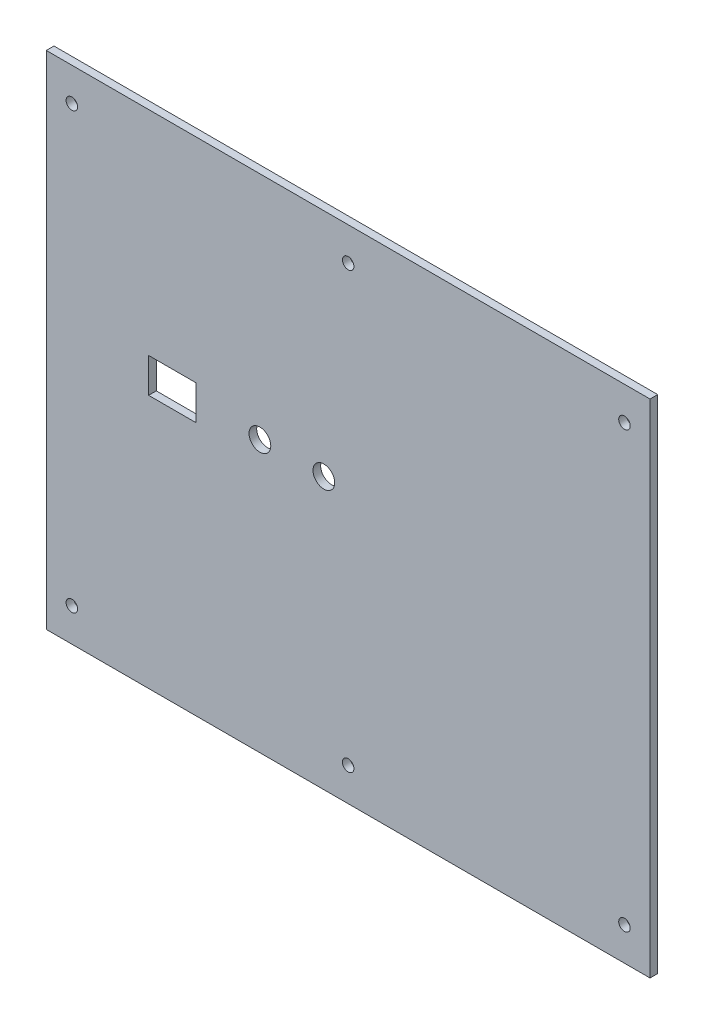
from build123d import *

# Parameters (mm, degrees)
SKETCH_1_W          = 236
SKETCH_1_H          = 196
SKETCH_1_R          = 2.25
EXTRUDE_1_DEPTH     = 3
SKETCH_2_R          = 4.25
SKETCH_2_W          = 18.5
SKETCH_2_H          = 13.5
CUT_EXTRUDE_1_DEPTH = 4


with BuildPart() as part:
    # Эскиз1 → Бобышка-Вытянуть1 (new body)
    with BuildSketch(Plane.XY):
        with Locations((118, 98)):
            Rectangle(SKETCH_1_W, SKETCH_1_H)
        with Locations((10, 183)):
            Circle(SKETCH_1_R, mode=Mode.SUBTRACT)
        with Locations((10, 13)):
            Circle(SKETCH_1_R, mode=Mode.SUBTRACT)
        with Locations((226, 183)):
            Circle(SKETCH_1_R, mode=Mode.SUBTRACT)
        with Locations((226, 13)):
            Circle(SKETCH_1_R, mode=Mode.SUBTRACT)
        with Locations((118, 183)):
            Circle(SKETCH_1_R, mode=Mode.SUBTRACT)
        with Locations((118, 13)):
            Circle(SKETCH_1_R, mode=Mode.SUBTRACT)
    extrude(amount=EXTRUDE_1_DEPTH)

    # Эскиз2 → Вырез-Вытянуть1 (cut, through all)
    with BuildSketch(Plane.XY.offset(3)):
        with Locations((108.5, 106)):
            Circle(SKETCH_2_R)
        with Locations((83.5, 106)):
            Circle(SKETCH_2_R)
        with Locations((49.25, 106)):
            Rectangle(SKETCH_2_W, SKETCH_2_H)
    extrude(amount=-CUT_EXTRUDE_1_DEPTH, mode=Mode.SUBTRACT)


solid = part.part
